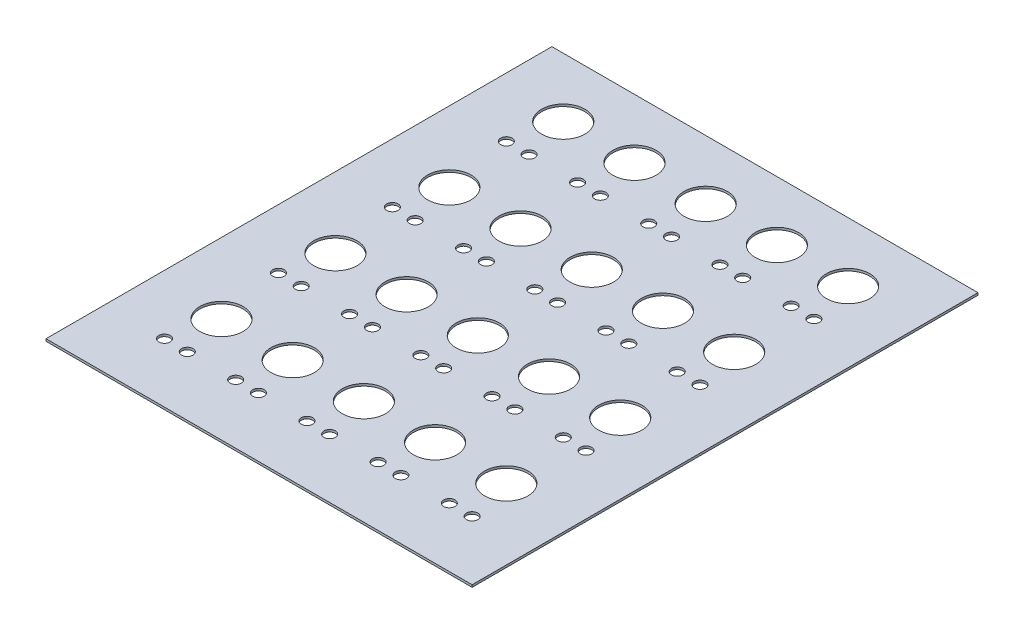
from build123d import *

# Parameters (mm, degrees)
SKETCH1_W           = 187
SKETCH1_H           = 222
SKETCH1_R           = 2.5
SKETCH1_R_2         = 9.5
BOSS_EXTRUDE1_DEPTH = 1


with BuildPart() as part:
    # Sketch1 → Boss-Extrude1 (new body)
    with BuildSketch(Plane(origin=(0, 0, 0), x_dir=(1, 0, 0), z_dir=(0, 1, 0))):
        with Locations((64.462554676, 36.018217652)):
            Rectangle(SKETCH1_W, SKETCH1_H)
        with Locations((-3.037445324, -48.981782348)):
            Circle(SKETCH1_R, mode=Mode.SUBTRACT)
        with Locations((6.962554676, -48.981782348)):
            Circle(SKETCH1_R, mode=Mode.SUBTRACT)
        with Locations((28.212554676, -48.981782348)):
            Circle(SKETCH1_R, mode=Mode.SUBTRACT)
        with Locations((38.212554676, -48.981782348)):
            Circle(SKETCH1_R, mode=Mode.SUBTRACT)
        with Locations((1.962554676, -28.981782348)):
            Circle(SKETCH1_R_2, mode=Mode.SUBTRACT)
        with Locations((33.212554676, -28.981782348)):
            Circle(SKETCH1_R_2, mode=Mode.SUBTRACT)
        with Locations((59.462554676, -48.981782348)):
            Circle(SKETCH1_R, mode=Mode.SUBTRACT)
        with Locations((69.462554676, -48.981782348)):
            Circle(SKETCH1_R, mode=Mode.SUBTRACT)
        with Locations((64.462554676, -28.981782348)):
            Circle(SKETCH1_R_2, mode=Mode.SUBTRACT)
        with Locations((90.712554676, -48.981782348)):
            Circle(SKETCH1_R, mode=Mode.SUBTRACT)
        with Locations((100.712554676, -48.981782348)):
            Circle(SKETCH1_R, mode=Mode.SUBTRACT)
        with Locations((95.712554676, -28.981782348)):
            Circle(SKETCH1_R_2, mode=Mode.SUBTRACT)
        with Locations((121.962554676, -48.981782348)):
            Circle(SKETCH1_R, mode=Mode.SUBTRACT)
        with Locations((131.962554676, -48.981782348)):
            Circle(SKETCH1_R, mode=Mode.SUBTRACT)
        with Locations((126.962554676, -28.981782348)):
            Circle(SKETCH1_R_2, mode=Mode.SUBTRACT)
        with Locations((-3.037445324, 1.018217652)):
            Circle(SKETCH1_R, mode=Mode.SUBTRACT)
        with Locations((6.962554676, 1.018217652)):
            Circle(SKETCH1_R, mode=Mode.SUBTRACT)
        with Locations((1.962554676, 21.018217652)):
            Circle(SKETCH1_R_2, mode=Mode.SUBTRACT)
        with Locations((28.212554676, 1.018217652)):
            Circle(SKETCH1_R, mode=Mode.SUBTRACT)
        with Locations((38.212554676, 1.018217652)):
            Circle(SKETCH1_R, mode=Mode.SUBTRACT)
        with Locations((33.212554676, 21.018217652)):
            Circle(SKETCH1_R_2, mode=Mode.SUBTRACT)
        with Locations((59.462554676, 1.018217652)):
            Circle(SKETCH1_R, mode=Mode.SUBTRACT)
        with Locations((69.462554676, 1.018217652)):
            Circle(SKETCH1_R, mode=Mode.SUBTRACT)
        with Locations((64.462554676, 21.018217652)):
            Circle(SKETCH1_R_2, mode=Mode.SUBTRACT)
        with Locations((90.712554676, 1.018217652)):
            Circle(SKETCH1_R, mode=Mode.SUBTRACT)
        with Locations((100.712554676, 1.018217652)):
            Circle(SKETCH1_R, mode=Mode.SUBTRACT)
        with Locations((95.712554676, 21.018217652)):
            Circle(SKETCH1_R_2, mode=Mode.SUBTRACT)
        with Locations((121.962554676, 1.018217652)):
            Circle(SKETCH1_R, mode=Mode.SUBTRACT)
        with Locations((131.962554676, 1.018217652)):
            Circle(SKETCH1_R, mode=Mode.SUBTRACT)
        with Locations((126.962554676, 21.018217652)):
            Circle(SKETCH1_R_2, mode=Mode.SUBTRACT)
        with Locations((-3.037445324, 51.018217652)):
            Circle(SKETCH1_R, mode=Mode.SUBTRACT)
        with Locations((6.962554676, 51.018217652)):
            Circle(SKETCH1_R, mode=Mode.SUBTRACT)
        with Locations((1.962554676, 71.018217652)):
            Circle(SKETCH1_R_2, mode=Mode.SUBTRACT)
        with Locations((28.212554676, 51.018217652)):
            Circle(SKETCH1_R, mode=Mode.SUBTRACT)
        with Locations((38.212554676, 51.018217652)):
            Circle(SKETCH1_R, mode=Mode.SUBTRACT)
        with Locations((33.212554676, 71.018217652)):
            Circle(SKETCH1_R_2, mode=Mode.SUBTRACT)
        with Locations((59.462554676, 51.018217652)):
            Circle(SKETCH1_R, mode=Mode.SUBTRACT)
        with Locations((69.462554676, 51.018217652)):
            Circle(SKETCH1_R, mode=Mode.SUBTRACT)
        with Locations((64.462554676, 71.018217652)):
            Circle(SKETCH1_R_2, mode=Mode.SUBTRACT)
        with Locations((90.712554676, 51.018217652)):
            Circle(SKETCH1_R, mode=Mode.SUBTRACT)
        with Locations((100.712554676, 51.018217652)):
            Circle(SKETCH1_R, mode=Mode.SUBTRACT)
        with Locations((95.712554676, 71.018217652)):
            Circle(SKETCH1_R_2, mode=Mode.SUBTRACT)
        with Locations((121.962554676, 51.018217652)):
            Circle(SKETCH1_R, mode=Mode.SUBTRACT)
        with Locations((131.962554676, 51.018217652)):
            Circle(SKETCH1_R, mode=Mode.SUBTRACT)
        with Locations((126.962554676, 71.018217652)):
            Circle(SKETCH1_R_2, mode=Mode.SUBTRACT)
        with Locations((-3.037445324, 101.018217652)):
            Circle(SKETCH1_R, mode=Mode.SUBTRACT)
        with Locations((6.962554676, 101.018217652)):
            Circle(SKETCH1_R, mode=Mode.SUBTRACT)
        with Locations((1.962554676, 121.018217652)):
            Circle(SKETCH1_R_2, mode=Mode.SUBTRACT)
        with Locations((28.212554676, 101.018217652)):
            Circle(SKETCH1_R, mode=Mode.SUBTRACT)
        with Locations((38.212554676, 101.018217652)):
            Circle(SKETCH1_R, mode=Mode.SUBTRACT)
        with Locations((33.212554676, 121.018217652)):
            Circle(SKETCH1_R_2, mode=Mode.SUBTRACT)
        with Locations((59.462554676, 101.018217652)):
            Circle(SKETCH1_R, mode=Mode.SUBTRACT)
        with Locations((69.462554676, 101.018217652)):
            Circle(SKETCH1_R, mode=Mode.SUBTRACT)
        with Locations((64.462554676, 121.018217652)):
            Circle(SKETCH1_R_2, mode=Mode.SUBTRACT)
        with Locations((90.712554676, 101.018217652)):
            Circle(SKETCH1_R, mode=Mode.SUBTRACT)
        with Locations((100.712554676, 101.018217652)):
            Circle(SKETCH1_R, mode=Mode.SUBTRACT)
        with Locations((95.712554676, 121.018217652)):
            Circle(SKETCH1_R_2, mode=Mode.SUBTRACT)
        with Locations((121.962554676, 101.018217652)):
            Circle(SKETCH1_R, mode=Mode.SUBTRACT)
        with Locations((131.962554676, 101.018217652)):
            Circle(SKETCH1_R, mode=Mode.SUBTRACT)
        with Locations((126.962554676, 121.018217652)):
            Circle(SKETCH1_R_2, mode=Mode.SUBTRACT)
    extrude(amount=BOSS_EXTRUDE1_DEPTH)


solid = part.part
